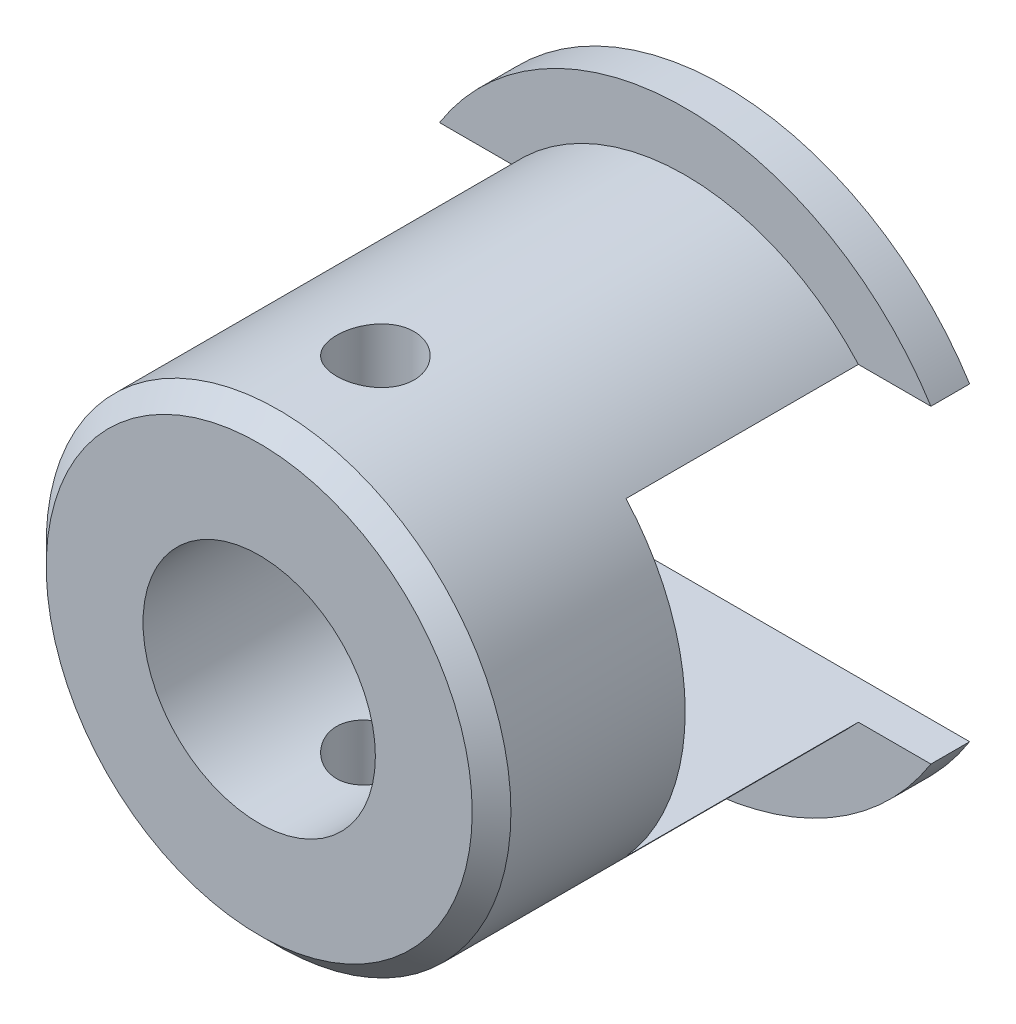
from build123d import *

# Parameters (mm, degrees)
ESQUISSE1_R                  = 7.5
BOSS_EXTRU_1_DEPTH           = 12
ESQUISSE2_R                  = 7.5
ESQUISSE2_R_2                = 6
ENL_V_MAT_EXTRU_1_DEPTH      = 11
ESQUISSE3_R                  = 3
ENL_V_MAT_EXTRU_2_DEPTH      = 5
ESQUISSE4_W                  = 19.769622122
ESQUISSE4_H                  = 8
ENL_V_MAT_EXTRU_3_DEPTH      = 7
ESQUISSE5_R                  = 1
ENL_V_MAT_EXTRU_4_DEPTH      = 7
ENL_V_MAT_EXTRU_4_DEPTH_BACK = 7
CHANFREIN1_SIZE              = 0.5


with BuildPart() as part:
    # Esquisse1 → Boss.-Extru.1 (new body)
    with BuildSketch(Plane.XY):
        Circle(ESQUISSE1_R)
    extrude(amount=BOSS_EXTRU_1_DEPTH)

    # Esquisse2 → Enlèv. mat.-Extru.1 (cut)
    with BuildSketch(Plane.XY.offset(12)):
        Circle(ESQUISSE2_R)
        Circle(ESQUISSE2_R_2, mode=Mode.SUBTRACT)
    extrude(amount=-ENL_V_MAT_EXTRU_1_DEPTH, mode=Mode.SUBTRACT)

    # Esquisse3 → Enlèv. mat.-Extru.2 (cut)
    with BuildSketch(Plane.XY.offset(12)):
        Circle(ESQUISSE3_R)
    extrude(amount=-ENL_V_MAT_EXTRU_2_DEPTH, mode=Mode.SUBTRACT)

    # Esquisse4 → Enlèv. mat.-Extru.3 (cut)
    with BuildSketch(Plane(origin=(0, 0, 0), x_dir=(-1, 0, 0), z_dir=(0, 0, -1))):
        Rectangle(ESQUISSE4_W, ESQUISSE4_H)
    extrude(amount=-ENL_V_MAT_EXTRU_3_DEPTH, mode=Mode.SUBTRACT)

    # Esquisse5 → Enlèv. mat.-Extru.4 (cut, two sides)
    with BuildSketch(Plane(origin=(0, 0, 0), x_dir=(1, 0, 0), z_dir=(0, 1, 0))) as enl_v_mat_extru_4_sk:
        with Locations((0, -9)):
            Circle(ESQUISSE5_R)
    extrude(amount=ENL_V_MAT_EXTRU_4_DEPTH, mode=Mode.SUBTRACT)
    extrude(enl_v_mat_extru_4_sk.sketch, amount=-ENL_V_MAT_EXTRU_4_DEPTH_BACK, mode=Mode.SUBTRACT)

    # Chanfrein1
    chanfrein1_edges = [part.edges().sort_by_distance(p)[0] for p in [
        (-6, 0, 12),
    ]]
    chamfer(chanfrein1_edges, length=CHANFREIN1_SIZE)


solid = part.part
